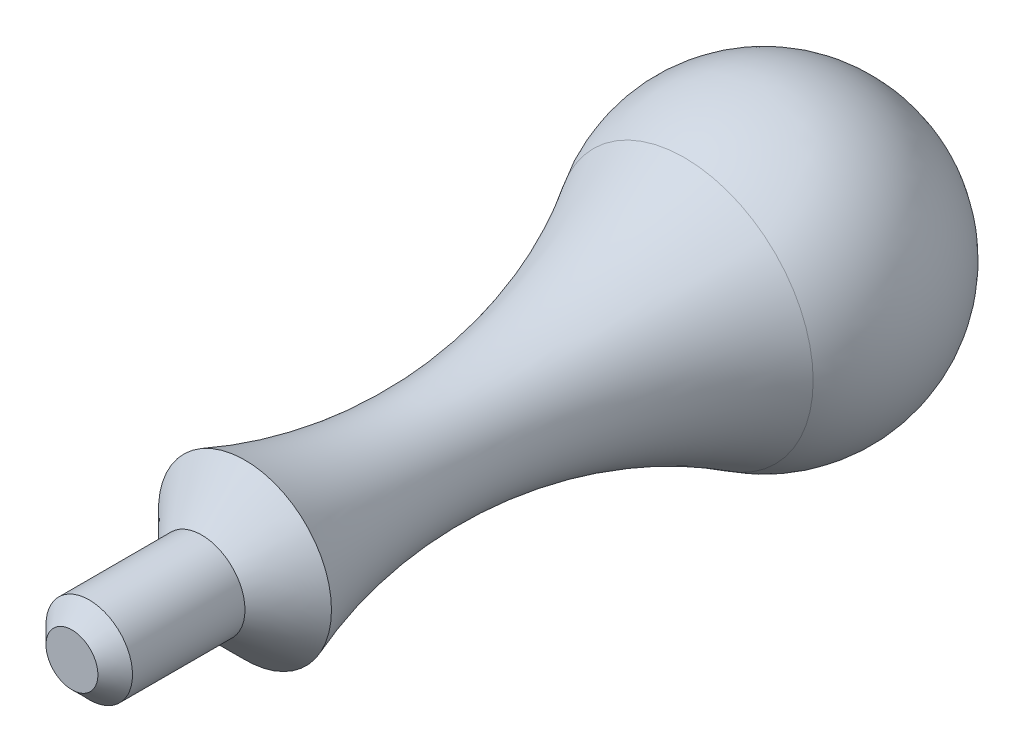
from build123d import *

# Parameters (mm, degrees)
CHAMFER1_SIZE = 1.27


with BuildPart() as part:
    # Sketch1 → Revolve1 (revolve)
    with BuildSketch(Plane(origin=(0, 0, 0), x_dir=(0, 0, -1), z_dir=(1, 0, 0))):
        with BuildLine():
            Line((-50.8, 3.175), (-41.275, 3.175))
            Line((-41.275, 3.175), (-38.1, 6.35))
            ThreePointArc((-38.1, 6.35), (-21.610199299, 4.14347303), (-5.843170842, 9.452248979))
            ThreePointArc((-5.843170842, 9.452248979), (5.41088811, 9.70618082), (11.1125, 0))
            Line((11.1125, 0), (-50.8, 0))
            Line((-50.8, 0), (-50.8, 3.175))
        make_face()
    revolve(axis=Axis((0, 0, 56.75283716), (0, 0, -1)))

    # Chamfer1
    chamfer1_edges = [part.edges().sort_by_distance(p)[0] for p in [
        (0, -3.175, 50.8),
    ]]
    chamfer(chamfer1_edges, length=CHAMFER1_SIZE)


solid = part.part
